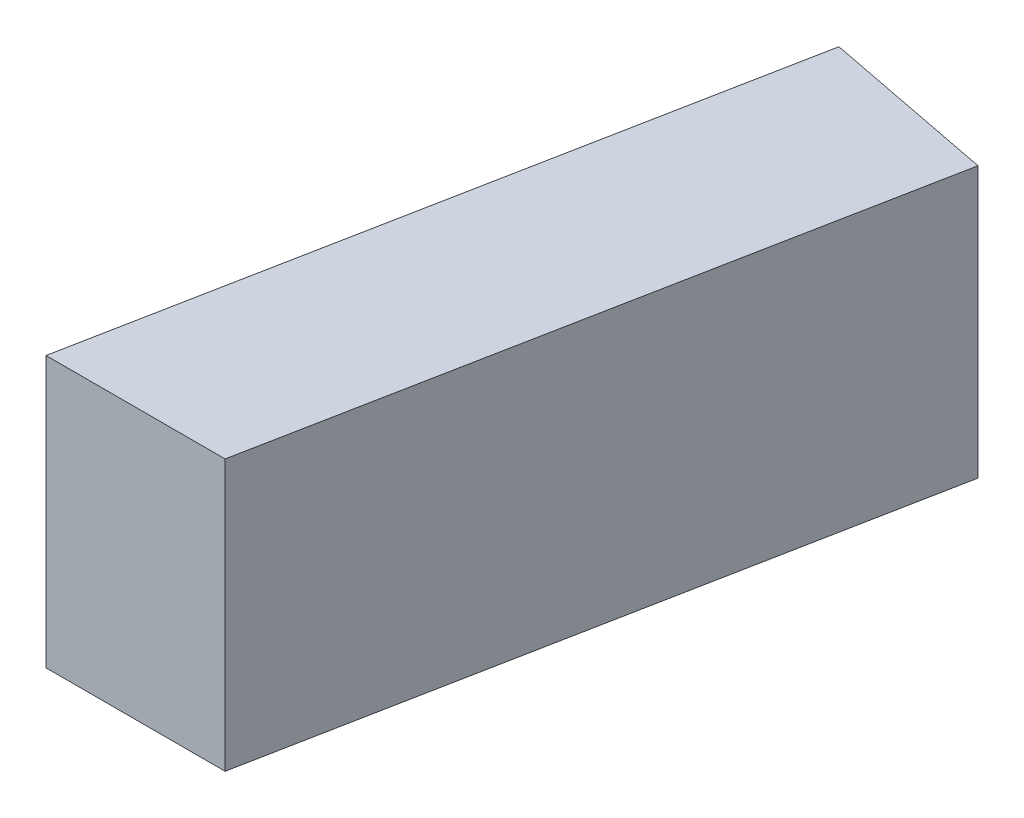
from build123d import *

# Parameters (mm, degrees)
BOSS_EXTRUDE1_DEPTH      = 5
BOSS_EXTRUDE1_DEPTH_BACK = 5


with BuildPart() as part:
    # Sketch1 → Boss-Extrude1 (new, two sides: drawn at the far end of the back side and taken through both)
    with BuildSketch(Plane(origin=(0, 0, 0), x_dir=(1, 0, 0), z_dir=(0, 1, 0)).offset(-BOSS_EXTRUDE1_DEPTH_BACK)):
        Polygon((0, 0), (4.770224884, 24.540679586), (11.150801577, 23.300421116), (6.621658517, 0), align=None)
    extrude(amount=BOSS_EXTRUDE1_DEPTH + BOSS_EXTRUDE1_DEPTH_BACK)


solid = part.part
